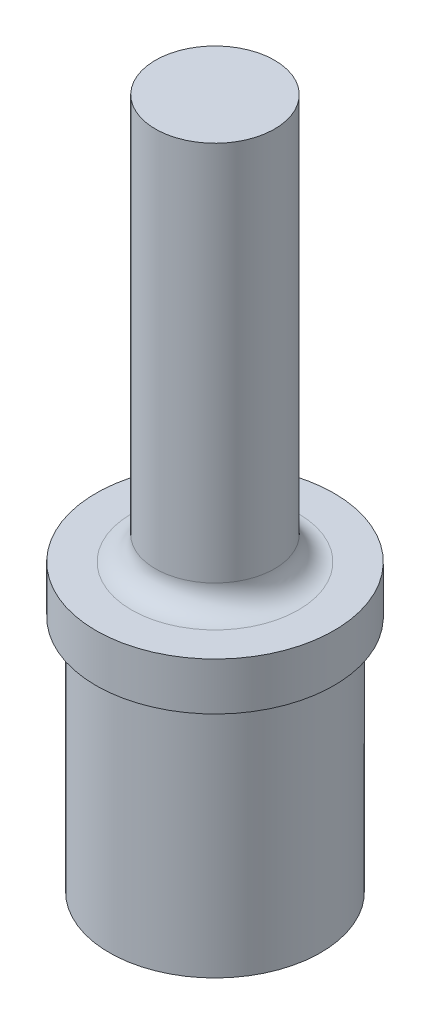
from build123d import *

# Parameters (mm, degrees)
FILLET1_R = 1.5875


with BuildPart() as part:
    # Sketch1 → Revolve1 (revolve)
    with BuildSketch(Plane.XY):
        Polygon((0, 0), (-3.9751, 0), (-3.9751, -26.9875), (-7.9375, -26.9875), (-7.9375, -30.1625), (-7.0485, -30.1625), (-7.0485, -46.0375), (-5.7785, -46.0375), (-5.7785, -33.869982951), (0, -30.7975), align=None)
    revolve(axis=Axis((0, 0, 0), (0, 1, 0)))

    # Fillet1
    fillet1_edges = [part.edges().sort_by_distance(p)[0] for p in [
        (3.9751, -26.9875, 0),
    ]]
    fillet(fillet1_edges, radius=FILLET1_R)


solid = part.part
